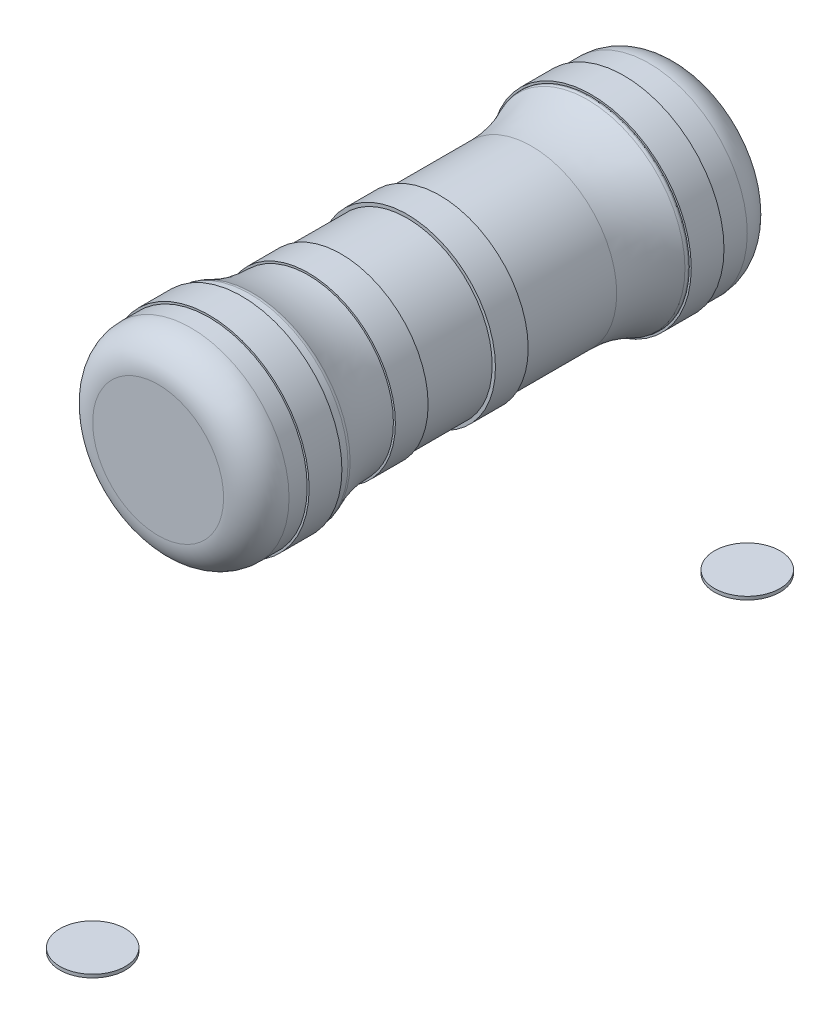
from build123d import *

# Parameters (mm, degrees)
FILLET1_R           = 2
SKETCH2_W           = 0.5
SKETCH2_H           = 0.029991608
SKETCH3_W           = 0.5
SKETCH3_H           = 0.05
SKETCH4_W           = 0.5
SKETCH4_H           = 0.03
SKETCH5_W           = 0.5
SKETCH5_H           = 0.03
SKETCH12_R          = 0.5
BOSS_EXTRUDE1_DEPTH = 0.05
SKETCH7_R           = 0.5
BOSS_EXTRUDE2_DEPTH = 0.05


with BuildPart() as part:
    # Sketch1 → Revolve1 (revolve)
    with BuildSketch(Plane(origin=(0, 0, 0), x_dir=(0, 0, -1), z_dir=(1, 0, 0))):
        with BuildLine():
            Line((2.6, 1.5), (3.5, 1.5))
            ThreePointArc((3.5, 1.5), (3.853553391, 1.353553391), (4, 1))
            Line((4, 1), (4, 0))
            Line((4, 0), (-4, 0))
            Line((-4, 0), (-4, 1))
            ThreePointArc((-4, 1), (-3.853553391, 1.353553391), (-3.5, 1.5))
            Line((-3.5, 1.5), (-2.6, 1.5))
            ThreePointArc((-2.6, 1.5), (-2.529289322, 1.470710678), (-2.5, 1.4))
            Line((-2.5, 1.4), (-2.5, 1.3))
            Line((-2.5, 1.3), (2.5, 1.3))
            Line((2.5, 1.3), (2.5, 1.4))
            ThreePointArc((2.5, 1.4), (2.529289322, 1.470710678), (2.6, 1.5))
        make_face()
    revolve(axis=Axis((0, 0, 30.94688027), (0, 0, -1)))

    # Fillet1
    fillet1_edges = [part.edges().sort_by_distance(p)[0] for p in [
        (0, -1.3, -2.5),
        (0, -1.3, 2.5),
    ]]
    fillet(fillet1_edges, radius=FILLET1_R)

    # Sketch2 → Revolve2 (revolve)
    with BuildSketch(Plane(origin=(0, 0, 0), x_dir=(0, 0, -1), z_dir=(1, 0, 0))):
        with Locations((-1.455572809, 1.314995804)):
            Rectangle(SKETCH2_W, SKETCH2_H)
    revolve(axis=Axis((0, 0, 2.184724067), (0, 0, -1)))

    # Sketch3 → Revolve3 (revolve)
    with BuildSketch(Plane(origin=(0, 0, 0), x_dir=(0, 0, -1), z_dir=(1, 0, 0))):
        with Locations((0.053199548, 1.325)):
            Rectangle(SKETCH3_W, SKETCH3_H)
    revolve(axis=Axis((0, 0, 0.48939527), (0, 0, -1)))

    # Sketch4 → Revolve4 (revolve)
    with BuildSketch(Plane(origin=(0, 0, 0), x_dir=(0, 0, -1), z_dir=(1, 0, 0))):
        with Locations((-2.972757668, 1.515)):
            Rectangle(SKETCH4_W, SKETCH4_H)
    revolve(axis=Axis((0, 0, 0.449237838), (0, 0, -1)))

    # Sketch5 → Revolve5 (revolve)
    with BuildSketch(Plane(origin=(0, 0, 0), x_dir=(0, 0, -1), z_dir=(1, 0, 0))):
        with Locations((2.864549609, 1.515)):
            Rectangle(SKETCH5_W, SKETCH5_H)
    revolve(axis=Axis((0, 0, 0.313399994), (0, 0, -1)))


with BuildPart() as body_2:
    # Sketch12 → Boss-Extrude1 (new body)
    with BuildSketch(Plane(origin=(0, -6, 0), x_dir=(-1, 0, 0), z_dir=(0, 1, 0))):
        with Locations((0, -5)):
            Circle(SKETCH12_R)
    extrude(amount=BOSS_EXTRUDE1_DEPTH)


with BuildPart() as body_3:
    # Sketch7 → Boss-Extrude2 (new body)
    with BuildSketch(Plane(origin=(0, -6, 0), x_dir=(-1, 0, 0), z_dir=(0, 1, 0))):
        with Locations((0, 5)):
            Circle(SKETCH7_R)
    extrude(amount=BOSS_EXTRUDE2_DEPTH)


solid = Compound([part.part, body_2.part, body_3.part])
